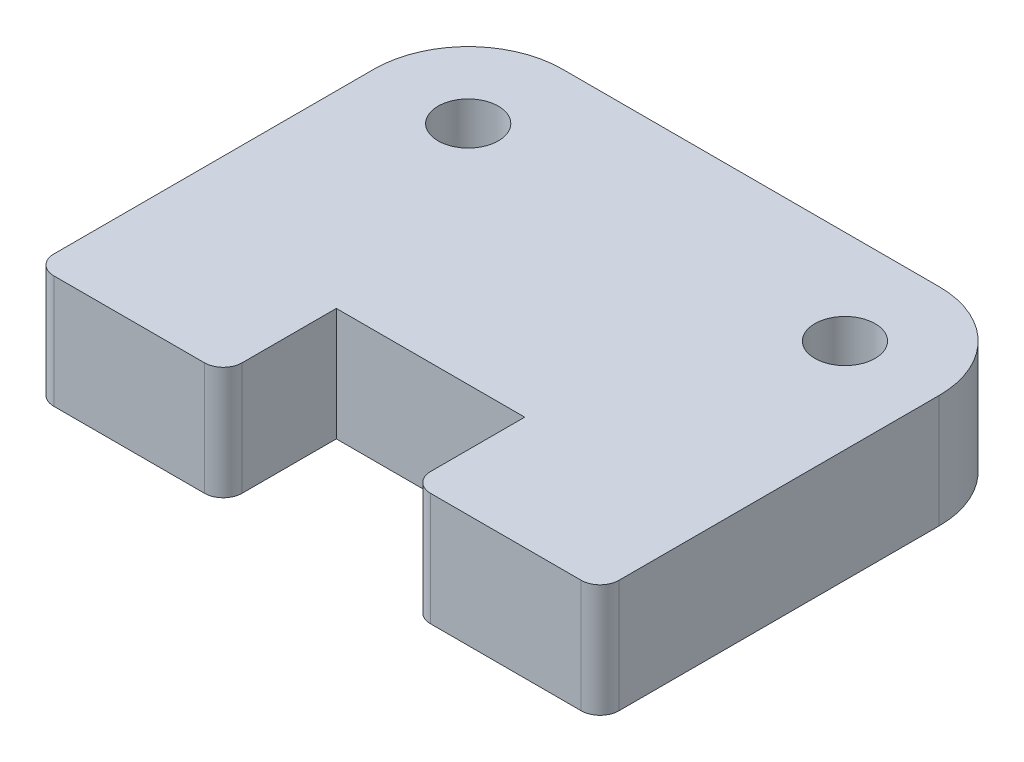
from build123d import *

# Parameters (mm, degrees)
SKETCH1_W              = 30
SKETCH1_H              = 17
BOSS_EXTRUDE1_DEPTH    = 6
SKETCH234_W            = 10
SKETCH234_H            = 6
BOSS_EXTRUDE234_DEPTH  = 6
FILLET134_R            = 1
SKETCH2341_W           = 10
SKETCH2341_H           = 6
BOSS_EXTRUDE2341_DEPTH = 6
FILLET1341_R           = 1
M3_CLEARANCE_HOLE1_D   = 3.2
FILLET1342_R           = 5


with BuildPart() as part:
    # Sketch1 → Boss-Extrude1 (new body)
    with BuildSketch(Plane(origin=(0, 0, 0), x_dir=(1, 0, 0), z_dir=(0, 1, 0))):
        with Locations((15, 8.5)):
            Rectangle(SKETCH1_W, SKETCH1_H)
    extrude(amount=BOSS_EXTRUDE1_DEPTH)

    # Sketch234 → Boss-Extrude234 (add)
    with BuildSketch(Plane(origin=(4.232221392, 0, 0), x_dir=(1, 0, 0), z_dir=(0, 0, 1))):
        with Locations((0.767778608, 3)):
            Rectangle(SKETCH234_W, SKETCH234_H)
    extrude(amount=BOSS_EXTRUDE234_DEPTH)

    # Fillet134
    fillet134_edges = [part.edges().sort_by_distance(p)[0] for p in [
        (0, 3, 6),
        (10, 3, 6),
    ]]
    fillet(fillet134_edges, radius=FILLET134_R)

    # Sketch2341 → Boss-Extrude2341 (add)
    with BuildSketch(Plane(origin=(24.232221392, 0, 0), x_dir=(1, 0, 0), z_dir=(0, 0, 1))):
        with Locations((0.767778608, 3)):
            Rectangle(SKETCH2341_W, SKETCH2341_H)
    extrude(amount=BOSS_EXTRUDE2341_DEPTH)

    # Fillet1341
    fillet1341_edges = [part.edges().sort_by_distance(p)[0] for p in [
        (30, 3, 6),
        (20, 3, 6),
    ]]
    fillet(fillet1341_edges, radius=FILLET1341_R)

    # M3 Clearance Hole1 (through all)
    with Locations(Plane(origin=(0, 6, 0), x_dir=(1, 0, 0), z_dir=(0, 1, 0))):
        with Locations((5, 12), (25, 12)):
            Hole(M3_CLEARANCE_HOLE1_D / 2)

    # Fillet1342
    fillet1342_edges = [part.edges().sort_by_distance(p)[0] for p in [
        (0, 3, -17),
        (30, 3, -17),
    ]]
    fillet(fillet1342_edges, radius=FILLET1342_R)


solid = part.part
